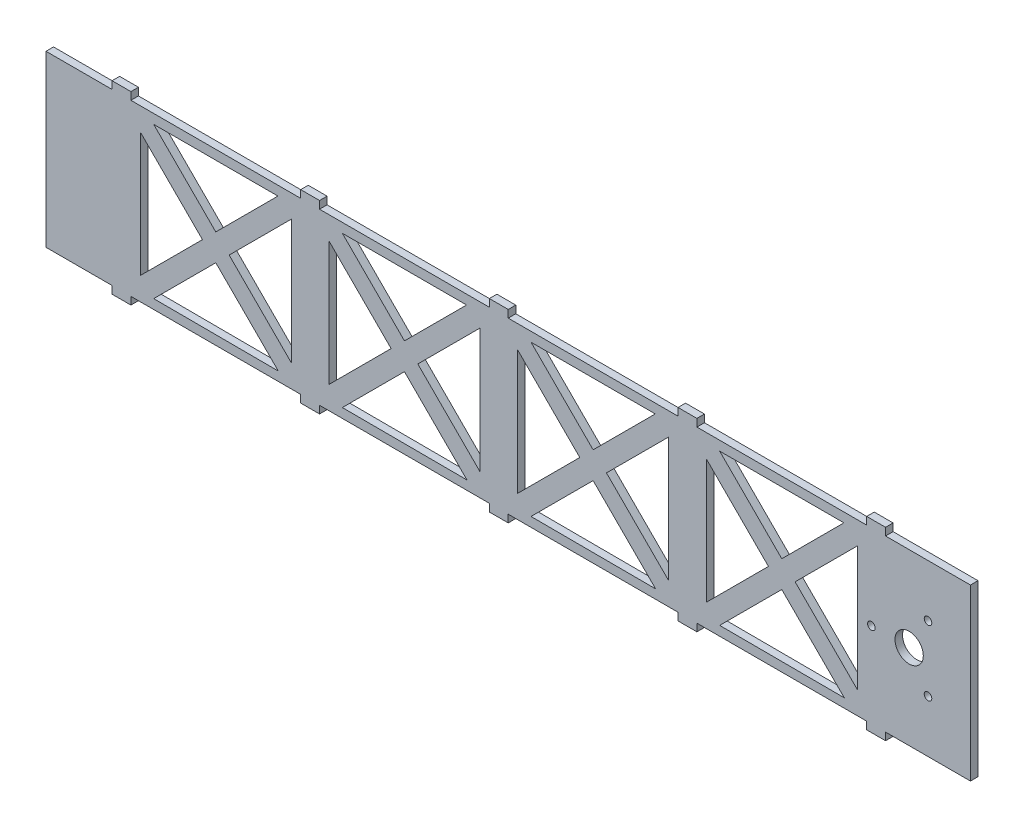
from build123d import *

# Parameters (mm, degrees)
SCHIZZO1_R                   = 7.5
SCHIZZO1_R_2                 = 2
ESTRUSIONE_ESTRUSIONE1_DEPTH = 4


with BuildPart() as part:
    # Schizzo1 → Estrusione-Estrusione1 (new body)
    with BuildSketch(Plane.XY):
        Polygon((0, 90), (0, 0), (35, 0), (35, -4), (45, -4), (45, 0), (135, 0), (135, -4), (145, -4), (145, 0), (235, 0), (235, -4), (245, -4), (245, 0), (335, 0), (335, -4), (345, -4), (345, 0), (435, 0), (435, -4), (445, -4), (445, 0), (490, 0), (490, 90), (445, 90), (445, 94), (435, 94), (435, 90), (345, 90), (345, 94), (335, 94), (335, 90), (245, 90), (245, 94), (235, 94), (235, 90), (145, 90), (145, 94), (135, 94), (135, 90), (45, 90), (45, 94), (35, 94), (35, 90), align=None)
        with Locations((457.5, 45)):
            Circle(SCHIZZO1_R, mode=Mode.SUBTRACT)
        with Locations((437.5, 45)):
            Circle(SCHIZZO1_R_2, mode=Mode.SUBTRACT)
        with Locations((467.5, 27.679491924)):
            Circle(SCHIZZO1_R_2, mode=Mode.SUBTRACT)
        with Locations((467.5, 62.320508076)):
            Circle(SCHIZZO1_R_2, mode=Mode.SUBTRACT)
        Polygon((50, 77.928932188), (50, 12.071067812), (82.928932188, 45), align=None, mode=Mode.SUBTRACT)
        Polygon((130, 77.928932188), (130, 12.071067812), (97.071067812, 45), align=None, mode=Mode.SUBTRACT)
        Polygon((57.071067812, 85), (90, 52.071067812), (122.928932188, 85), align=None, mode=Mode.SUBTRACT)
        Polygon((123.1448388, 4.784093388), (57.077189669, 5.006121857), (90, 37.928932188), align=None, mode=Mode.SUBTRACT)
        Polygon((150, 77.928932188), (150, 12.071067812), (182.928932188, 45), align=None, mode=Mode.SUBTRACT)
        Polygon((230, 77.928932188), (230, 12.071067812), (197.071067812, 45), align=None, mode=Mode.SUBTRACT)
        Polygon((157.071067812, 85), (190, 52.071067812), (222.928932188, 85), align=None, mode=Mode.SUBTRACT)
        Polygon((223.1448388, 4.784093388), (157.077189669, 5.006121857), (190, 37.928932188), align=None, mode=Mode.SUBTRACT)
        Polygon((250, 77.928932188), (250, 12.071067812), (282.928932188, 45), align=None, mode=Mode.SUBTRACT)
        Polygon((330, 77.928932188), (330, 12.071067812), (297.071067812, 45), align=None, mode=Mode.SUBTRACT)
        Polygon((257.071067812, 85), (290, 52.071067812), (322.928932188, 85), align=None, mode=Mode.SUBTRACT)
        Polygon((323.1448388, 4.784093388), (257.077189669, 5.006121857), (290, 37.928932188), align=None, mode=Mode.SUBTRACT)
        Polygon((350, 77.928932188), (350, 12.071067812), (382.928932188, 45), align=None, mode=Mode.SUBTRACT)
        Polygon((430, 77.928932188), (430, 12.071067812), (397.071067812, 45), align=None, mode=Mode.SUBTRACT)
        Polygon((357.071067812, 85), (390, 52.071067812), (422.928932188, 85), align=None, mode=Mode.SUBTRACT)
        Polygon((423.1448388, 4.784093388), (357.077189669, 5.006121857), (390, 37.928932188), align=None, mode=Mode.SUBTRACT)
    extrude(amount=ESTRUSIONE_ESTRUSIONE1_DEPTH)


solid = part.part
